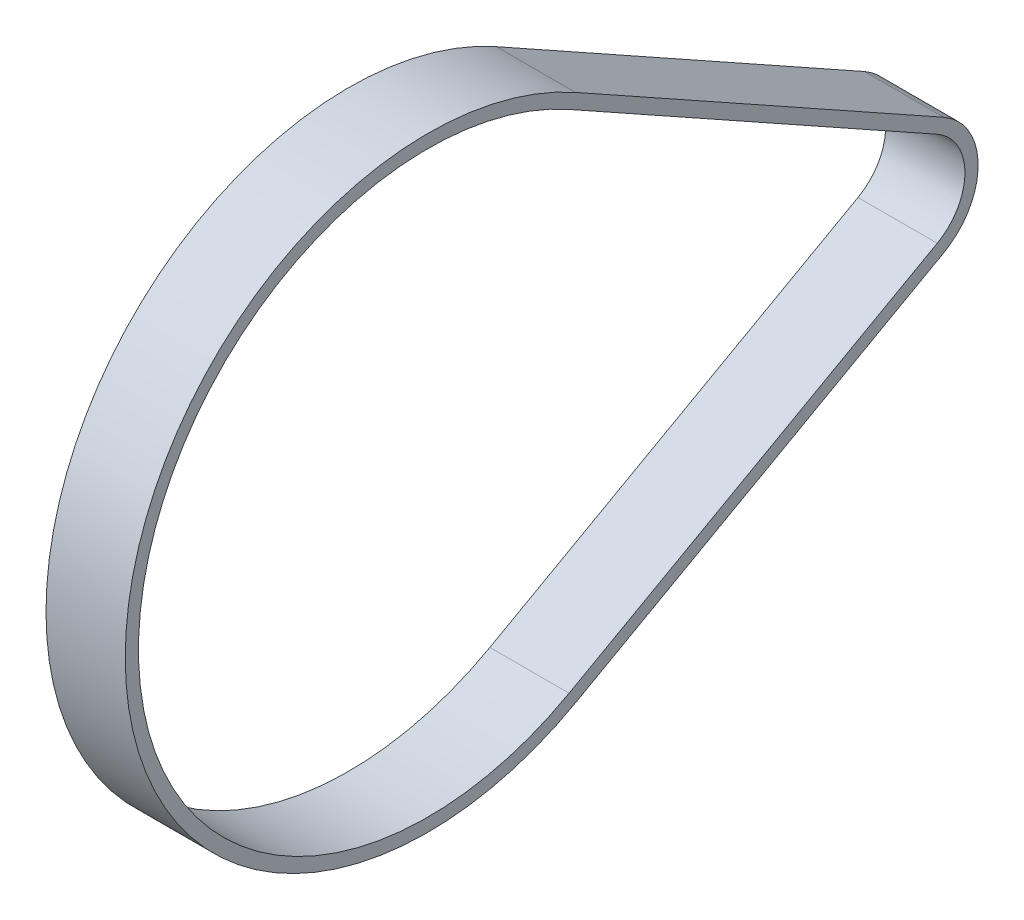
from build123d import *

# Parameters (mm, degrees)
BOSS_EXTRUDE1_DEPTH = 7.5


with BuildPart() as part:
    # Sketch1 → Boss-Extrude1 (new body, symmetric)
    with BuildSketch(Plane(origin=(0, 0, 0), x_dir=(0, 0, -1), z_dir=(1, 0, 0))):
        with BuildLine():
            Line((-17.768131265, 50.024946562), (51.909746228, 11.116654792))
            ThreePointArc((51.909746228, 11.116654792), (58.434575318, 0), (51.909746228, -11.116654792))
            Line((51.909746228, -11.116654792), (-17.768131265, -50.024946562))
            ThreePointArc((-17.768131265, -50.024946562), (-102.997959384, 0), (-17.768131265, 50.024946562))
        make_face()
        with BuildLine():
            Line((-18.986984069, 47.842196498), (50.690893424, 8.933904727))
            ThreePointArc((50.690893424, 8.933904727), (55.934575318, 0), (50.690893424, -8.933904727))
            Line((50.690893424, -8.933904727), (-18.986984069, -47.842196498))
            ThreePointArc((-18.986984069, -47.842196498), (-100.497959384, 0), (-18.986984069, 47.842196498))
        make_face(mode=Mode.SUBTRACT)
    extrude(amount=BOSS_EXTRUDE1_DEPTH, both=True)


solid = part.part
